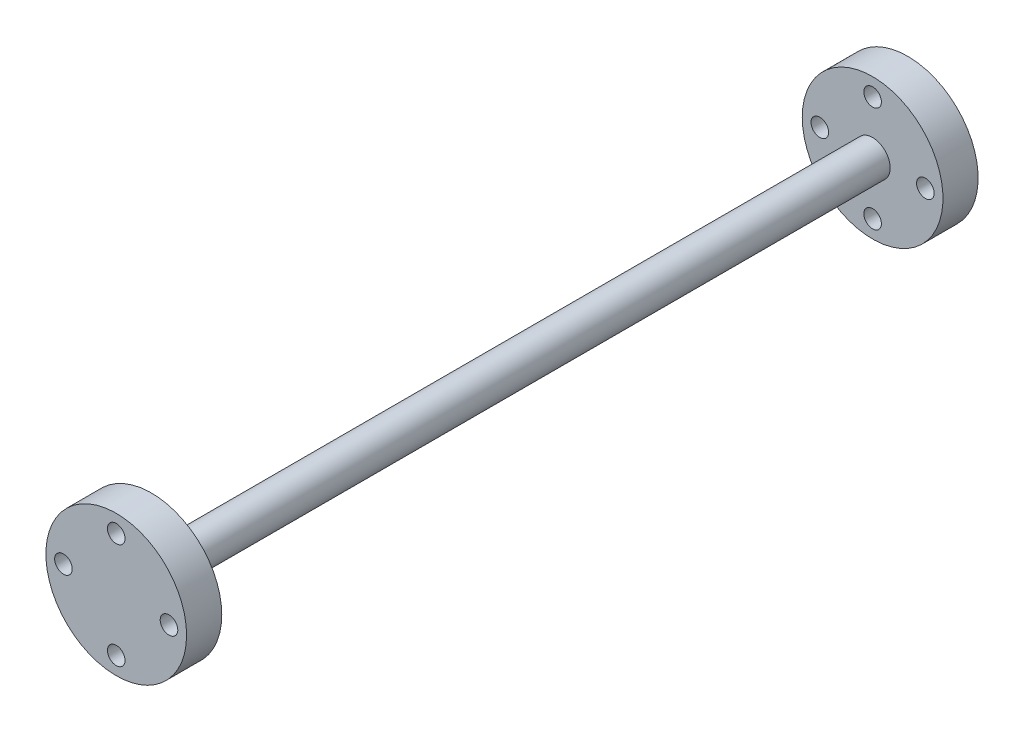
from build123d import *

# Parameters (mm, degrees)
SKETCH1_R                = 5
BOSS_EXTRUDE1_DEPTH      = 105
BOSS_EXTRUDE1_DEPTH_BACK = 100
SKETCH2_R                = 20
SKETCH2_R_2              = 2.5
BOSS_EXTRUDE2_DEPTH      = 10
SKETCH3_R                = 20
SKETCH3_R_2              = 2.5
BOSS_EXTRUDE3_DEPTH      = 10


with BuildPart() as part:
    # Sketch1 → Boss-Extrude1 (new body, two sides)
    with BuildSketch(Plane.XY) as boss_extrude1_sk:
        Circle(SKETCH1_R)
    extrude(amount=BOSS_EXTRUDE1_DEPTH)
    extrude(boss_extrude1_sk.sketch, amount=-BOSS_EXTRUDE1_DEPTH_BACK)

    # Sketch2 → Boss-Extrude2 (add)
    with BuildSketch(Plane.XY.offset(105)):
        Circle(SKETCH2_R)
        with Locations((0, 15)):
            Circle(SKETCH2_R_2, mode=Mode.SUBTRACT)
        with Locations((15, 0)):
            Circle(SKETCH2_R_2, mode=Mode.SUBTRACT)
        with Locations((0, -15)):
            Circle(SKETCH2_R_2, mode=Mode.SUBTRACT)
        with Locations((-15, 0)):
            Circle(SKETCH2_R_2, mode=Mode.SUBTRACT)
    extrude(amount=BOSS_EXTRUDE2_DEPTH)

    # Sketch3 → Boss-Extrude3 (add)
    with BuildSketch(Plane(origin=(0, 0, -100), x_dir=(-1, 0, 0), z_dir=(0, 0, -1))):
        Circle(SKETCH3_R)
        with Locations((0, 15)):
            Circle(SKETCH3_R_2, mode=Mode.SUBTRACT)
        with Locations((-15, 0)):
            Circle(SKETCH3_R_2, mode=Mode.SUBTRACT)
        with Locations((0, -15)):
            Circle(SKETCH3_R_2, mode=Mode.SUBTRACT)
        with Locations((15, 0)):
            Circle(SKETCH3_R_2, mode=Mode.SUBTRACT)
    extrude(amount=BOSS_EXTRUDE3_DEPTH)


solid = part.part
